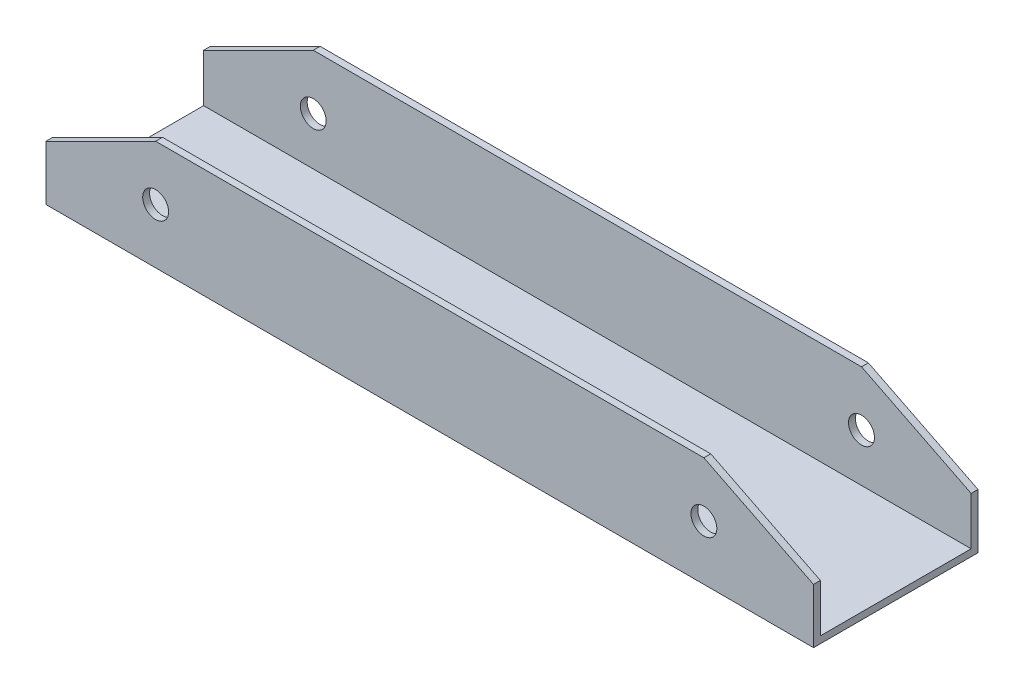
from build123d import *

# Parameters (mm, degrees)
SKETCH2_W           = 38.1
SKETCH2_H           = 38.1
SKETCH2_W_2         = 34.925
SKETCH2_H_2         = 34.925
BOSS_EXTRUDE1_DEPTH = 228.6
SKETCH3_R           = 3
CUT_EXTRUDE1_DEPTH  = 228.6


with BuildPart() as part:
    # Sketch2 → Boss-Extrude1 (new body)
    with BuildSketch(Plane(origin=(0, 0, 0), x_dir=(0, 0, -1), z_dir=(1, 0, 0))):
        with Locations((19.05, 19.05)):
            Rectangle(SKETCH2_W, SKETCH2_H)
        with Locations((19.05, 19.05)):
            Rectangle(SKETCH2_W_2, SKETCH2_H_2, mode=Mode.SUBTRACT)
    extrude(amount=BOSS_EXTRUDE1_DEPTH)

    # Sketch3 → Cut-Extrude1 (cut)
    with BuildSketch(Plane.XY):
        with Locations((25.4, 12.7)):
            Circle(SKETCH3_R)
        with Locations((152.4, 12.7)):
            Circle(SKETCH3_R)
        Polygon((0, 12.7), (25.4, 25.4), (152.4, 25.4), (177.8, 12.7), (177.8, 0), (228.6, 0), (228.6, 38.1), (0, 38.1), align=None)
    extrude(amount=-CUT_EXTRUDE1_DEPTH, mode=Mode.SUBTRACT)


solid = part.part
